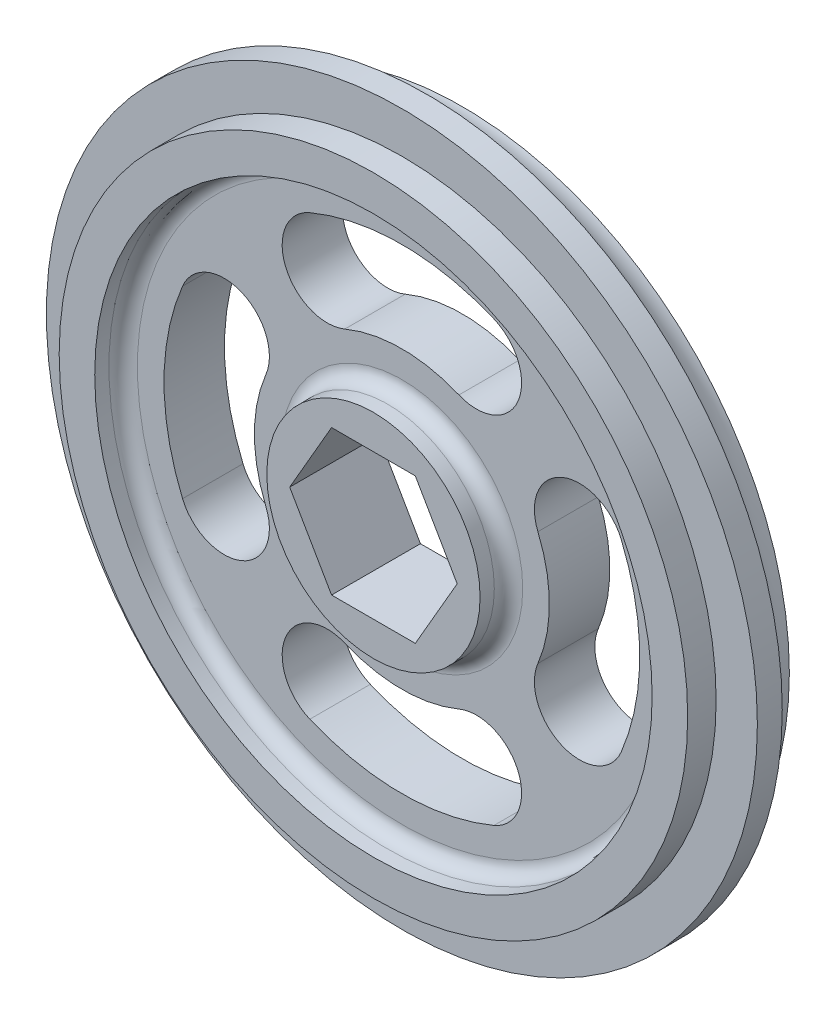
from build123d import *

# Parameters (mm, degrees)
SKETCH1_R                         = 31.75
HEX_AXEL_CUTOUT_OUTSIDE_RIM_DEPTH = 15.875
SKETCH3_R                         = 31.75
SKETCH3_R_2                       = 28.067
PIPE_STEP_DEPTH                   = 2.54
SKETCH5_R                         = 24.892
SKETCH5_R_2                       = 9.525
SPOKE_STEP_DEPTH                  = 2.54
SLOTS_DEPTH                       = 14.335
FILLET1_R                         = 1.27
SKETCH7_W                         = 163.08703459
SKETCH7_H                         = 168.65885573
MIDCUT_DEPTH                      = 8.9375


with BuildPart() as part:
    # Sketch1 → Hex Axel Cutout & Outside Rim (new body)
    with BuildSketch(Plane.XY):
        Circle(SKETCH1_R)
        Polygon((-7.478995387, 0), (-3.739497694, -6.477), (3.739497694, -6.477), (7.478995387, 0), (3.739497694, 6.477), (-3.739497694, 6.477), align=None, mode=Mode.SUBTRACT)
    extrude(amount=HEX_AXEL_CUTOUT_OUTSIDE_RIM_DEPTH)

    # Sketch3 → Pipe Step (cut)
    with BuildSketch(Plane.XY.offset(15.875)):
        Circle(SKETCH3_R)
        Circle(SKETCH3_R_2, mode=Mode.SUBTRACT)
    pipe_step = extrude(amount=-PIPE_STEP_DEPTH, mode=Mode.SUBTRACT)

    # Step Mirror: Pipe Step across plane
    add(pipe_step.mirror(Plane.XY.offset(7.9375)), mode=Mode.SUBTRACT)

    # Sketch4 → Poly Cord Groove (revolve, cut)
    with BuildSketch(Plane(origin=(0, 0, 0), x_dir=(0, 0, -1), z_dir=(1, 0, 0))):
        with BuildLine():
            Line((-4.7625, 31.75), (-11.1125, 31.75))
            ThreePointArc((-11.1125, 31.75), (-7.9375, 29.21), (-4.7625, 31.75))
        make_face()
    revolve(axis=Axis((0, 0, 13.335), (0, 0, -1)), mode=Mode.SUBTRACT)

    # Sketch5 → Spoke Step (cut)
    with BuildSketch(Plane(origin=(0, 0, 0), x_dir=(-1, 0, 0), z_dir=(0, 0, -1))):
        Circle(SKETCH5_R)
        Circle(SKETCH5_R_2, mode=Mode.SUBTRACT)
    spoke_step = extrude(amount=-SPOKE_STEP_DEPTH, mode=Mode.SUBTRACT)

    # Spoke Step Mirror: Spoke Step across plane
    add(spoke_step.mirror(Plane.XY.offset(7.9375)), mode=Mode.SUBTRACT)

    # Sketch6 → Slots (cut, through all)
    with BuildSketch(Plane.XY.offset(13.335)):
        with BuildLine():
            ThreePointArc((19.589209778, -8.218410987), (21.243338223, 0), (19.589209778, 8.218410987))
            ThreePointArc((19.589209778, 8.218410987), (14.307589254, 10.378115507), (12.147884733, 5.096494983))
            ThreePointArc((12.147884733, 5.096494983), (13.173661777, 0), (12.147884733, -5.096494983))
            ThreePointArc((12.147884733, -5.096494983), (14.307589254, -10.378115507), (19.589209778, -8.218410987))
        make_face()
        with BuildLine():
            ThreePointArc((-8.218410987, -19.589209778), (0, -21.243338223), (8.218410987, -19.589209778))
            ThreePointArc((8.218410987, -19.589209778), (10.378115507, -14.307589254), (5.096494983, -12.147884733))
            ThreePointArc((5.096494983, -12.147884733), (0, -13.173661777), (-5.096494983, -12.147884733))
            ThreePointArc((-5.096494983, -12.147884733), (-10.378115507, -14.307589254), (-8.218410987, -19.589209778))
        make_face()
        with BuildLine():
            ThreePointArc((-19.589209778, 8.218410987), (-21.243338223, 0), (-19.589209778, -8.218410987))
            ThreePointArc((-19.589209778, -8.218410987), (-14.307589254, -10.378115507), (-12.147884733, -5.096494983))
            ThreePointArc((-12.147884733, -5.096494983), (-13.173661777, 0), (-12.147884733, 5.096494983))
            ThreePointArc((-12.147884733, 5.096494983), (-14.307589254, 10.378115507), (-19.589209778, 8.218410987))
        make_face()
        with BuildLine():
            ThreePointArc((8.218410987, 19.589209778), (0, 21.243338223), (-8.218410987, 19.589209778))
            ThreePointArc((-8.218410987, 19.589209778), (-10.378115507, 14.307589254), (-5.096494983, 12.147884733))
            ThreePointArc((-5.096494983, 12.147884733), (0, 13.173661777), (5.096494983, 12.147884733))
            ThreePointArc((5.096494983, 12.147884733), (10.378115507, 14.307589254), (8.218410987, 19.589209778))
        make_face()
    extrude(amount=-SLOTS_DEPTH, mode=Mode.SUBTRACT)

    # Fillet1
    fillet1_edges = [part.edges().sort_by_distance(p)[0] for p in [
        (24.892, 0, 2.54),
        (9.525, 0, 2.54),
        (24.892, 0, 13.335),
        (9.525, 0, 13.335),
    ]]
    fillet(fillet1_edges, radius=FILLET1_R)

    # Sketch7 → MidCut (cut, through all)
    with BuildSketch(Plane.XY.offset(7.9375)):
        with Locations((2.006221024, 3.627486548)):
            Rectangle(SKETCH7_W, SKETCH7_H)
    extrude(amount=-MIDCUT_DEPTH, mode=Mode.SUBTRACT)


solid = part.part
